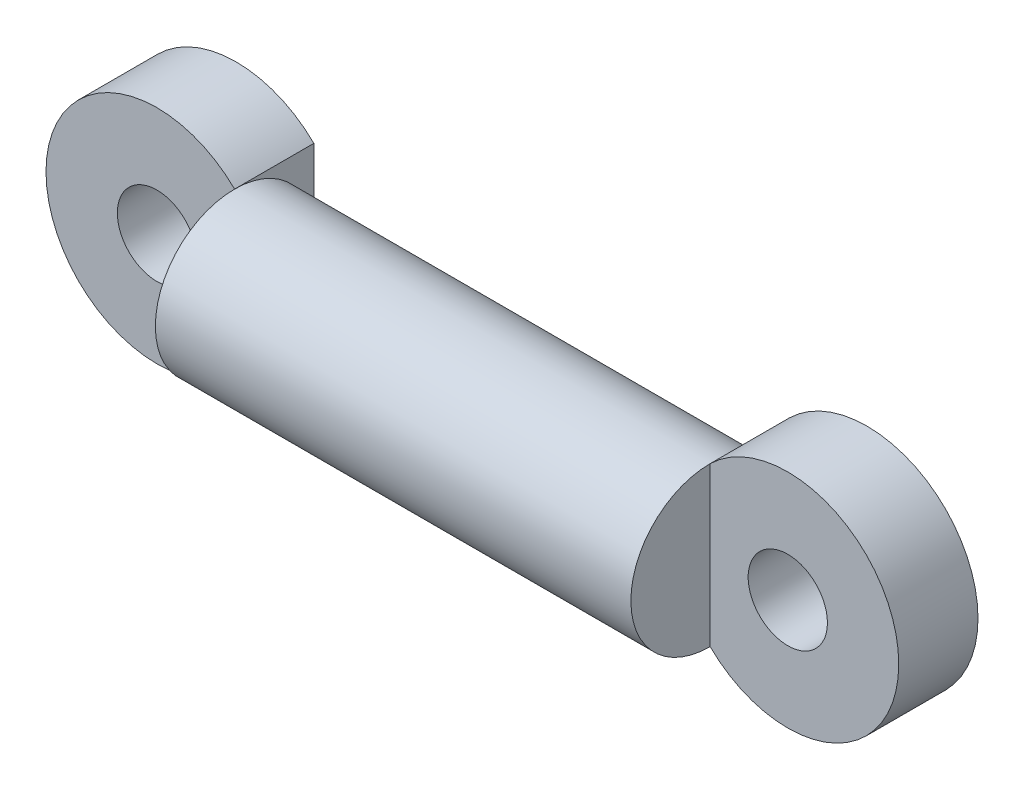
from build123d import *

# Parameters (mm, degrees)
SKETCH1_W           = 30
SKETCH1_H           = 5
SKETCH3_R           = 2.5
BOSS_EXTRUDE2_DEPTH = 5


with BuildPart() as part:
    # Sketch1 → Revolve-Thin1 (revolve)
    with BuildSketch(Plane.XY):
        with Locations((0, 2.5)):
            Rectangle(SKETCH1_W, SKETCH1_H)
    revolve(axis=Axis((-15, 0, 0), (1, 0, 0)))

    # Sketch3 → Boss-Extrude2 (add)
    with BuildSketch(Plane.XY):
        with BuildLine():
            Line((15, 5), (15, -5))
            ThreePointArc((15, -5), (26.898979486, 0), (15, 5))
        make_face()
        with Locations((19.898979486, 0)):
            Circle(SKETCH3_R, mode=Mode.SUBTRACT)
        with BuildLine():
            Line((-15, -5), (-15, 5))
            ThreePointArc((-15, 5), (-26.898979486, 0), (-15, -5))
        make_face()
        with Locations((-19.898979486, 0)):
            Circle(SKETCH3_R, mode=Mode.SUBTRACT)
    extrude(amount=-BOSS_EXTRUDE2_DEPTH)


solid = part.part
